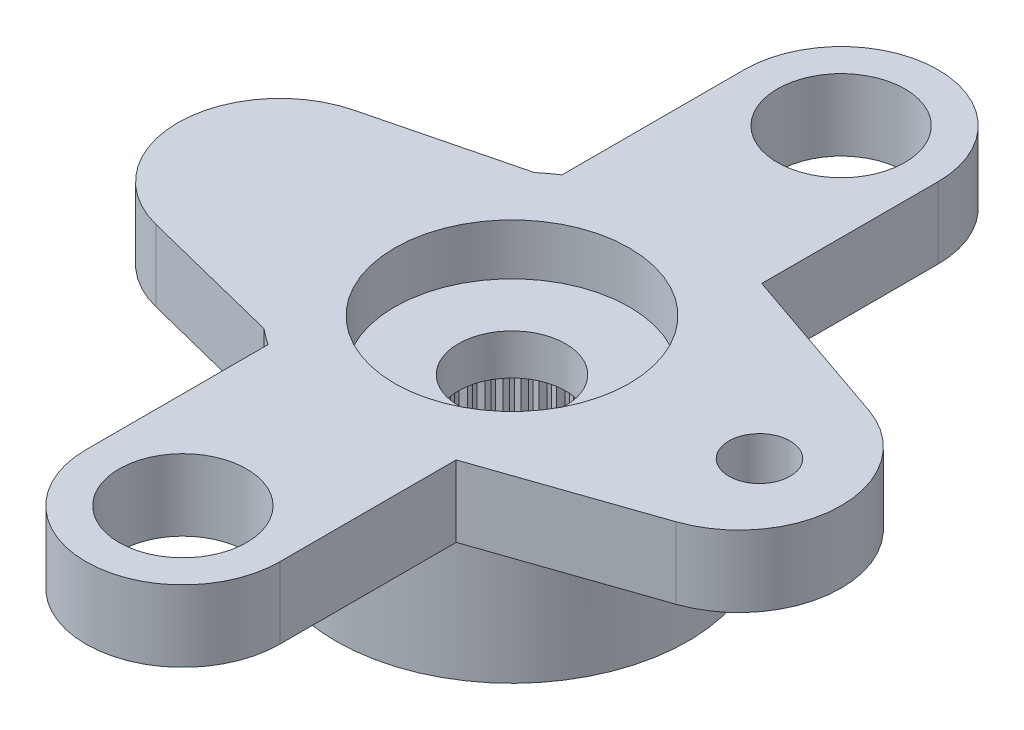
from build123d import *

# Parameters (mm, degrees)
RESSALTO_EXTRUS_O1_DEPTH = 1.4
ESBO_O2_R                = 3.45
RESSALTO_EXTRUS_O2_DEPTH = 2.4
RESSALTO_EXTRUS_O3_DEPTH = 1.4
FURO2_D                  = 1.2
RESSALTO_EXTRUS_O4_DEPTH = 1.4
FURO3_D                  = 2.5
PADR_OCIRCULAR1_COUNT    = 2
FURO4_D                  = 4.95
FURO4_DEPTH              = 2
FURO5_D                  = 4.6
FURO5_DEPTH              = 1
FURO6_D                  = 2.1
RESSALTO_EXTRUS_O5_DEPTH = 2
PADR_OCIRCULAR2_COUNT    = 60


with BuildPart() as part:
    # Esboço1 → Ressalto-extrusão1 (new body)
    with BuildSketch(Plane(origin=(0, 0, 0), x_dir=(1, 0, 0), z_dir=(0, 1, 0))):
        with BuildLine():
            Line((-5.037147328, 1.9397648), (-2.209072203, 2.65))
            ThreePointArc((-2.209072203, 2.65), (3.45, 0), (-2.209072203, -2.65))
            Line((-2.209072203, -2.65), (-5.037147328, -1.9397648))
            ThreePointArc((-5.037147328, -1.9397648), (-6.55, 0), (-5.037147328, 1.9397648))
        make_face()
    extrude(amount=-RESSALTO_EXTRUS_O1_DEPTH)

    # Esboço2 → Ressalto-extrusão2 (add)
    with BuildSketch(Plane.XZ.offset(1.4)):
        Circle(ESBO_O2_R)
    extrude(amount=RESSALTO_EXTRUS_O2_DEPTH)

    # Esboço12 → Ressalto-extrusão3 (add)
    with BuildSketch(Plane(origin=(0, 0, 0), x_dir=(1, 0, 0), z_dir=(0, 1, 0))):
        with BuildLine():
            Line((1.124157303, 3.261712795), (5.101685393, 1.890847997))
            ThreePointArc((5.101685393, 1.890847997), (6.45, 0), (5.101685393, -1.890847997))
            Line((5.101685393, -1.890847997), (1.124157303, -3.261712795))
            ThreePointArc((1.124157303, -3.261712795), (3.45, 0), (1.124157303, 3.261712795))
        make_face()
    extrude(amount=-RESSALTO_EXTRUS_O3_DEPTH)

    # Furo2 (through all)
    with Locations(Plane(origin=(0, 0, 0), x_dir=(1, 0, 0), z_dir=(0, 1, 0))):
        with Locations((4.85, 0)):
            Hole(FURO2_D / 2)

    # Esboço16 → Ressalto-extrusão4 (add)
    with BuildSketch(Plane(origin=(0, 0, 0), x_dir=(1, 0, 0), z_dir=(0, 1, 0))):
        with BuildLine():
            Line((-1.9, -6.45), (-1.9, 6.45))
            ThreePointArc((-1.9, 6.45), (0, 8.35), (1.9, 6.45))
            Line((1.9, 6.45), (1.9, -6.45))
            ThreePointArc((1.9, -6.45), (0, -8.35), (-1.9, -6.45))
        make_face()
    extrude(amount=-RESSALTO_EXTRUS_O4_DEPTH)

    # Furo3 (through all)
    with Locations(Plane(origin=(0, 0, 0), x_dir=(1, 0, 0), z_dir=(0, 1, 0))):
        with Locations((0, -6.45)):
            furo3 = Hole(FURO3_D / 2)

    # PadrãoCircular1: Furo3 ×2 about axis
    padr_ocircular1_axis = Axis((0, 0, 0), (0, 1, 0))
    for i in range(1, PADR_OCIRCULAR1_COUNT):
        add(furo3.rotate(padr_ocircular1_axis, i * 360 / PADR_OCIRCULAR1_COUNT), mode=Mode.SUBTRACT)

    # Furo4
    with Locations(Plane(origin=(0, -3.8, 0), x_dir=(-1, 0, 0), z_dir=(0, -1, 0))):
        with Locations((0, 0)):
            Hole(FURO4_D / 2, depth=FURO4_DEPTH)

    # Furo5
    with Locations(Plane(origin=(0, 0, 0), x_dir=(1, 0, 0), z_dir=(0, 1, 0))):
        with Locations((0, 0)):
            Hole(FURO5_D / 2, depth=FURO5_DEPTH)

    # Furo6 (through all)
    with Locations(Plane(origin=(0, 0, 0), x_dir=(1, 0, 0), z_dir=(0, 1, 0))):
        with Locations((0, 0)):
            Hole(FURO6_D / 2)

    # Esboço11 → Ressalto-extrusão5 (add)
    with BuildSketch(Plane.XZ.offset(3.8)):
        with BuildLine():
            Line((-0.098056786, 2.473056786), (0, 2.375))
            Line((0, 2.375), (0.098056786, 2.473056786))
            ThreePointArc((0.098056786, 2.473056786), (0, 2.475), (-0.098056786, 2.473056786))
        make_face()
    ressalto_extrus_o5 = extrude(amount=-RESSALTO_EXTRUS_O5_DEPTH)

    # PadrãoCircular2: Ressalto-extrusão5 ×60 about axis
    padr_ocircular2_axis = Axis((0, 0, 0), (0, 1, 0))
    for i in range(1, PADR_OCIRCULAR2_COUNT):
        add(ressalto_extrus_o5.rotate(padr_ocircular2_axis, i * 360 / PADR_OCIRCULAR2_COUNT))


solid = part.part
